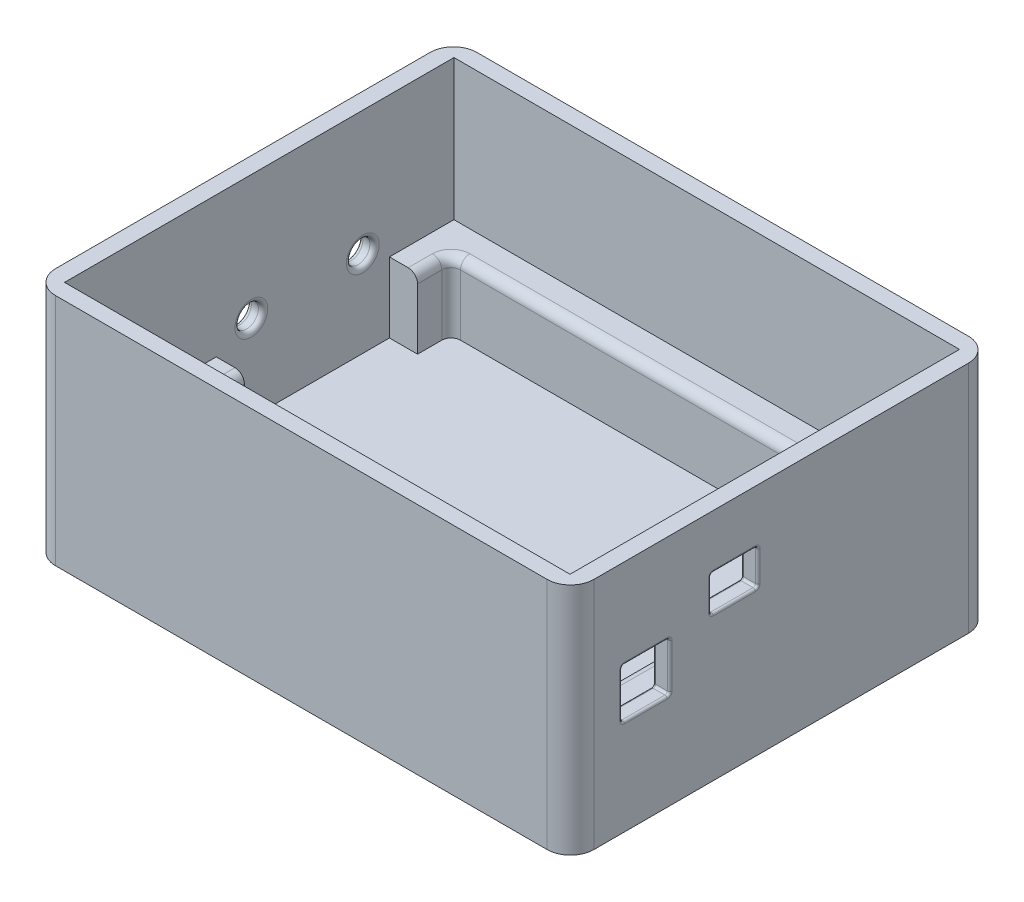
from build123d import *

# Parameters (mm, degrees)
SKETCH2_W           = 115
SKETCH2_H           = 90
BOSS_EXTRUDE1_DEPTH = 50
FILLET1_R           = 5
SKETCH3_W           = 108
SKETCH3_H           = 83.2
CUT_EXTRUDE1_DEPTH  = 30
SKETCH4_W           = 96
SKETCH4_H           = 70
CUT_EXTRUDE2_DEPTH  = 15
FILLET2_R           = 2
SKETCH5_W           = 6
SKETCH5_H           = 37.000676584
CUT_EXTRUDE3_DEPTH  = 15
SKETCH7_W           = 6
SKETCH7_H           = 25.403449595
CUT_EXTRUDE5_DEPTH  = 15
SKETCH8_R           = 2.5
CUT_EXTRUDE6_DEPTH  = 10
FILLET3_R           = 1
SKETCH9_W           = 10.16
SKETCH9_H           = 10.4
CUT_EXTRUDE7_DEPTH  = 10
FILLET9_R           = 0.5
SKETCH10_W          = 10
SKETCH10_H          = 7.5
CUT_EXTRUDE8_DEPTH  = 10
FILLET10_R          = 0.5


with BuildPart() as part:
    # Sketch2 → Boss-Extrude1 (new body)
    with BuildSketch(Plane(origin=(0, 0, 0), x_dir=(1, 0, 0), z_dir=(0, 1, 0))):
        Rectangle(SKETCH2_W, SKETCH2_H)
    extrude(amount=BOSS_EXTRUDE1_DEPTH)

    # Fillet1
    fillet1_edges = [part.edges().sort_by_distance(p)[0] for p in [
        (57.5, 25, 45),
        (-57.5, 25, 45),
        (-57.5, 25, -45),
        (57.5, 25, -45),
    ]]
    fillet(fillet1_edges, radius=FILLET1_R)

    # Sketch3 → Cut-Extrude1 (cut)
    with BuildSketch(Plane(origin=(0, 50, 0), x_dir=(1, 0, 0), z_dir=(0, 1, 0))):
        Rectangle(SKETCH3_W, SKETCH3_H)
    extrude(amount=-CUT_EXTRUDE1_DEPTH, mode=Mode.SUBTRACT)

    # Sketch4 → Cut-Extrude2 (cut)
    with BuildSketch(Plane(origin=(0, 20, 0), x_dir=(1, 0, 0), z_dir=(0, 1, 0))):
        Rectangle(SKETCH4_W, SKETCH4_H)
    extrude(amount=-CUT_EXTRUDE2_DEPTH, mode=Mode.SUBTRACT)

    # Fillet2
    fillet2_edges = [part.edges().sort_by_distance(p)[0] for p in [
        (48, 12.5, -35),
        (48, 12.5, 35),
        (-48, 12.5, 35),
        (-48, 12.5, -35),
        (48, 20, 0),
        (0, 20, -35),
        (-48, 20, 0),
        (0, 20, 35),
    ]]
    fillet(fillet2_edges, radius=FILLET2_R)

    # Sketch5 → Cut-Extrude3 (cut)
    with BuildSketch(Plane(origin=(0, 20, 0), x_dir=(1, 0, 0), z_dir=(0, 1, 0))):
        with Locations((-51, 9.319200259)):
            Rectangle(SKETCH5_W, SKETCH5_H)
    extrude(amount=-CUT_EXTRUDE3_DEPTH, mode=Mode.SUBTRACT)

    # Sketch7 → Cut-Extrude5 (cut)
    with BuildSketch(Plane(origin=(0, 20, 0), x_dir=(1, 0, 0), z_dir=(0, 1, 0))):
        with Locations((51, 20.50224057)):
            Rectangle(SKETCH7_W, SKETCH7_H)
    extrude(amount=-CUT_EXTRUDE5_DEPTH, mode=Mode.SUBTRACT)

    # Sketch8 → Cut-Extrude6 (cut)
    with BuildSketch(Plane(origin=(-54, 0, 0), x_dir=(0, 0, -1), z_dir=(1, 0, 0))):
        with Locations((22.12592041, 23.41148)):
            Circle(SKETCH8_R)
        with Locations((-1.690767369, 23.41148)):
            Circle(SKETCH8_R)
    extrude(amount=-CUT_EXTRUDE6_DEPTH, mode=Mode.SUBTRACT)

    # Fillet3
    fillet3_edges = [part.edges().sort_by_distance(p)[0] for p in [
        (-57.5, 23.41148, -19.62592041),
        (-54, 23.41148, -19.62592041),
        (-57.5, 23.41148, 4.190767369),
        (-54, 23.41148, 4.190767369),
    ]]
    fillet(fillet3_edges, radius=FILLET3_R)

    # Sketch9 → Cut-Extrude7 (cut)
    with BuildSketch(Plane.ZY.offset(-54)):
        with Locations((28.900001247, 25.71148)):
            Rectangle(SKETCH9_W, SKETCH9_H)
    extrude(amount=-CUT_EXTRUDE7_DEPTH, mode=Mode.SUBTRACT)

    # Fillet9
    fillet9_edges = [part.edges().sort_by_distance(p)[0] for p in [
        (57.5, 25.71148, 23.820001247),
        (55.75, 20.51148, 23.820001247),
        (57.5, 30.91148, 28.900001247),
        (55.75, 30.91148, 23.820001247),
        (57.5, 25.71148, 33.980001247),
        (55.75, 30.91148, 33.980001247),
        (57.5, 20.51148, 28.900001247),
        (55.75, 20.51148, 33.980001247),
        (54, 25.71148, 23.820001247),
        (54, 20.51148, 28.900001247),
        (54, 25.71148, 33.980001247),
        (54, 30.91148, 28.900001247),
    ]]
    fillet(fillet9_edges, radius=FILLET9_R)

    # Sketch10 → Cut-Extrude8 (cut)
    with BuildSketch(Plane(origin=(57.5, 0, 0), x_dir=(0, 0, -1), z_dir=(1, 0, 0))):
        with Locations((-10, 34.725408503)):
            Rectangle(SKETCH10_W, SKETCH10_H)
    extrude(amount=-CUT_EXTRUDE8_DEPTH, mode=Mode.SUBTRACT)

    # Fillet10
    fillet10_edges = [part.edges().sort_by_distance(p)[0] for p in [
        (54, 34.725408503, 15),
        (55.75, 30.975408503, 15),
        (54, 38.475408503, 10),
        (55.75, 38.475408503, 15),
        (54, 34.725408503, 5),
        (55.75, 38.475408503, 5),
        (54, 30.975408503, 10),
        (55.75, 30.975408503, 5),
        (57.5, 34.725408503, 15),
        (57.5, 30.975408503, 10),
        (57.5, 34.725408503, 5),
        (57.5, 38.475408503, 10),
    ]]
    fillet(fillet10_edges, radius=FILLET10_R)


solid = part.part
